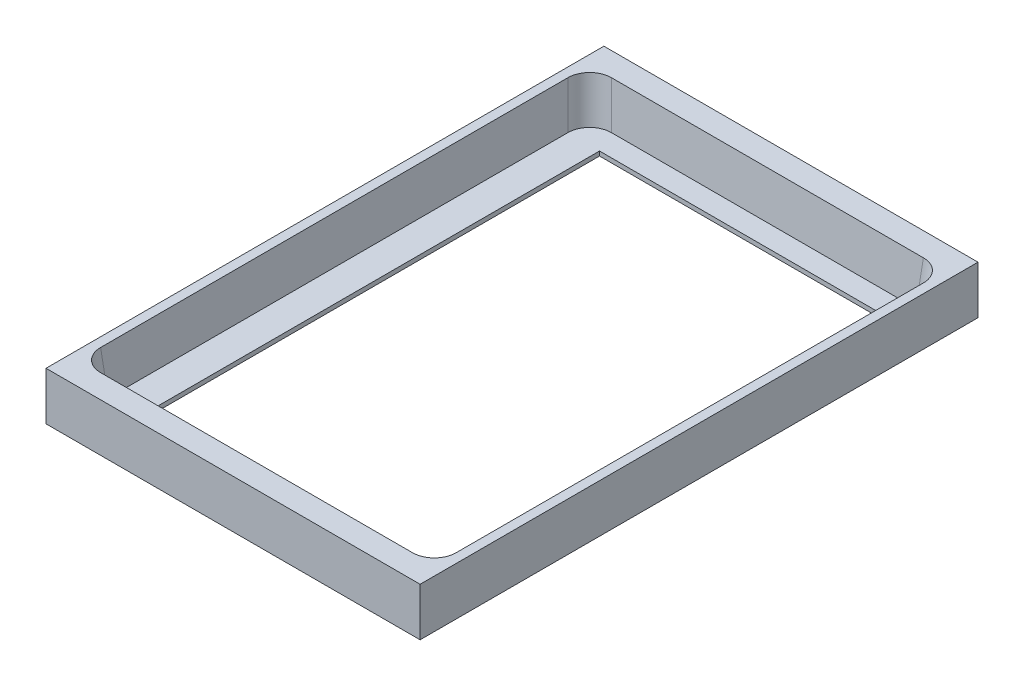
from build123d import *

# Parameters (mm, degrees)
SKETCH1_W           = 85.5
SKETCH1_H           = 127.5
BOSS_EXTRUDE1_DEPTH = 10
SKETCH2_W           = 79.5
SKETCH2_H           = 115
CUT_EXTRUDE1_DEPTH  = 10
CUT_EXTRUDE1_TAPER  = -5
SKETCH4_W           = 85.5
SKETCH4_H           = 127.5
BOSS_EXTRUDE3_DEPTH = 1
SKETCH6_W           = 65
SKETCH6_H           = 105
CUT_EXTRUDE2_DEPTH  = 1.1
FILLET2_R           = 5
FILLET3_R           = 5
FILLET4_R           = 5
FILLET5_R           = 5


with BuildPart() as part:
    # Sketch1 → Boss-Extrude1 (new body)
    with BuildSketch(Plane(origin=(0, 0, 0), x_dir=(1, 0, 0), z_dir=(0, 1, 0))):
        Rectangle(SKETCH1_W, SKETCH1_H)
    extrude(amount=BOSS_EXTRUDE1_DEPTH)

    # Sketch2 → Cut-Extrude1 (cut)
    with BuildSketch(Plane.XZ):
        Rectangle(SKETCH2_W, SKETCH2_H)
    extrude(amount=-CUT_EXTRUDE1_DEPTH, taper=CUT_EXTRUDE1_TAPER, mode=Mode.SUBTRACT)

    # Sketch4 → Boss-Extrude3 (add)
    with BuildSketch(Plane.XZ):
        Rectangle(SKETCH4_W, SKETCH4_H)
    extrude(amount=BOSS_EXTRUDE3_DEPTH)

    # Sketch6 → Cut-Extrude2 (cut)
    with BuildSketch(Plane.XZ.offset(1)):
        Rectangle(SKETCH6_W, SKETCH6_H)
    extrude(amount=-CUT_EXTRUDE2_DEPTH, mode=Mode.SUBTRACT)

    # Fillet2
    fillet2_edges = [part.edges().sort_by_distance(p)[0] for p in [
        (40.187443318, 5, 57.937443318),
    ]]
    fillet(fillet2_edges, radius=FILLET2_R)

    # Fillet3
    fillet3_edges = [part.edges().sort_by_distance(p)[0] for p in [
        (-40.187443318, 5, 57.937443318),
    ]]
    fillet(fillet3_edges, radius=FILLET3_R)

    # Fillet4
    fillet4_edges = [part.edges().sort_by_distance(p)[0] for p in [
        (-40.187443318, 5, -57.937443318),
    ]]
    fillet(fillet4_edges, radius=FILLET4_R)

    # Fillet5
    fillet5_edges = [part.edges().sort_by_distance(p)[0] for p in [
        (40.187443318, 5, -57.937443318),
    ]]
    fillet(fillet5_edges, radius=FILLET5_R)


solid = part.part
